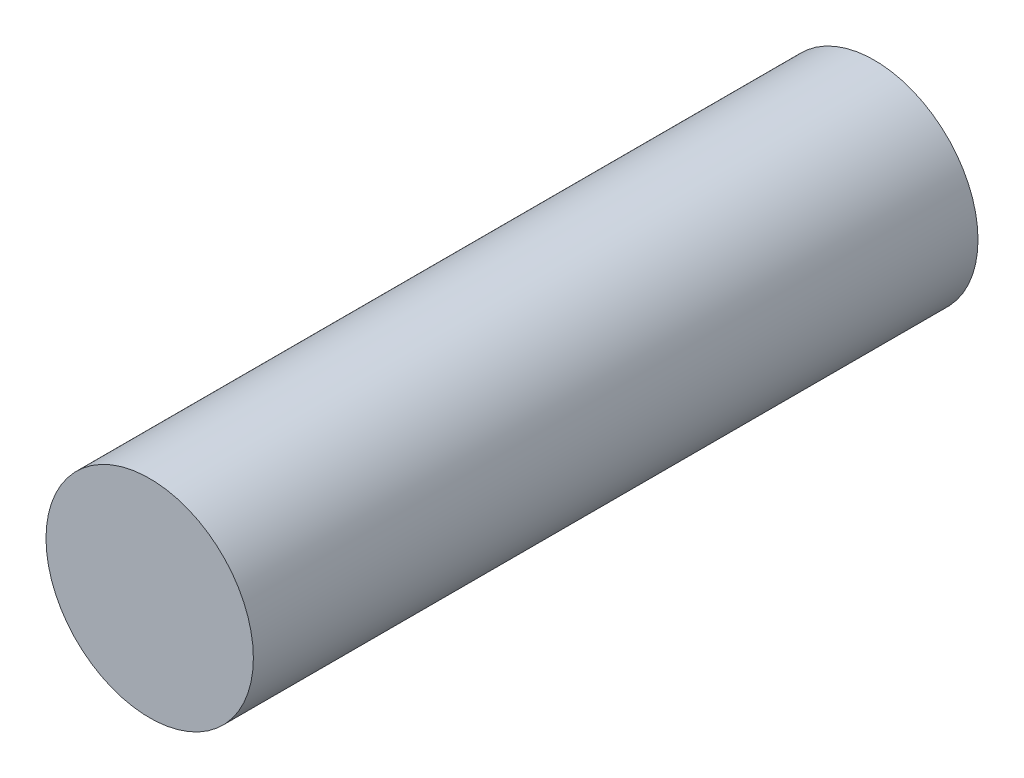
from build123d import *

# Parameters (mm, degrees)
SKETCH1_R           = 9.3
BOSS_EXTRUDE1_DEPTH = 65


with BuildPart() as part:
    # Sketch1 → Boss-Extrude1 (new body)
    with BuildSketch(Plane.XY):
        Circle(SKETCH1_R)
    extrude(amount=BOSS_EXTRUDE1_DEPTH)


solid = part.part
